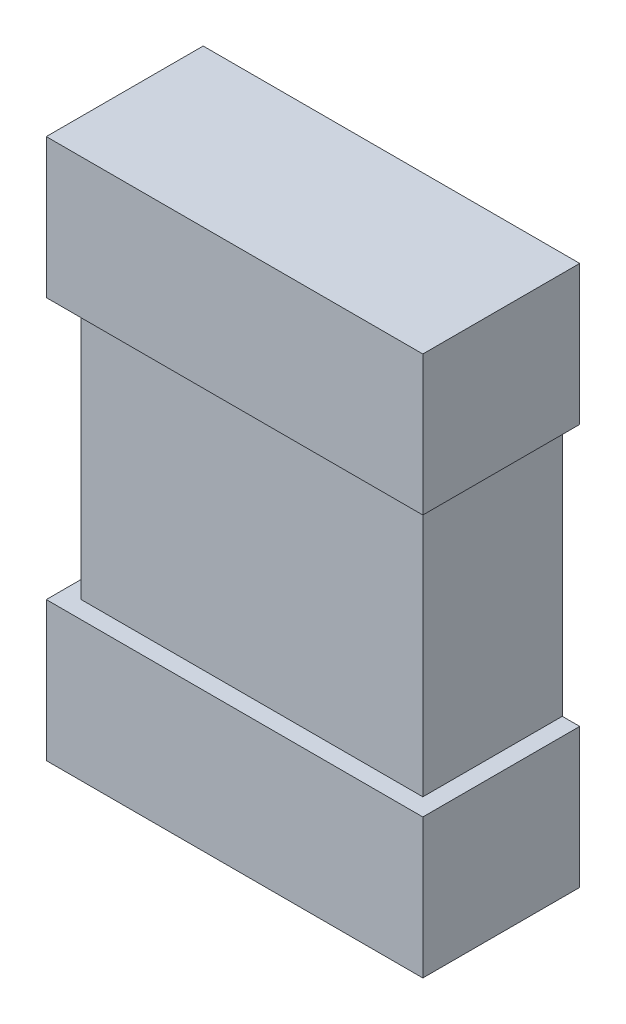
from build123d import *

# Parameters (mm, degrees)
COMPONENT_OUTLINE_W = 1.08
COMPONENT_OUTLINE_H = 1.55
EXTRUDE1_DEPTH      = 0.45
SKETCH2_W           = 0.05
SKETCH2_H           = 0.75
CUT_EXTRUDE1_DEPTH  = 1.45
SKETCH3_W           = 0.05
SKETCH3_H           = 0.75
CUT_EXTRUDE2_DEPTH  = 2.03


with BuildPart() as part:
    # COMPONENT_OUTLINE → Extrude1 (new body)
    with BuildSketch(Plane.XY):
        Rectangle(COMPONENT_OUTLINE_W, COMPONENT_OUTLINE_H)
    extrude(amount=EXTRUDE1_DEPTH)

    # Sketch2 → Cut-Extrude1 (cut, through all)
    with BuildSketch(Plane.XY.offset(0.45)):
        with Locations((-0.515, 0)):
            Rectangle(SKETCH2_W, SKETCH2_H)
        with Locations((0.515, 0)):
            Rectangle(SKETCH2_W, SKETCH2_H)
    extrude(amount=-CUT_EXTRUDE1_DEPTH, mode=Mode.SUBTRACT)

    # Sketch3 → Cut-Extrude2 (cut, through all)
    with BuildSketch(Plane(origin=(0.49, 0, 0), x_dir=(0, 0, -1), z_dir=(1, 0, 0))):
        with Locations((-0.425, 0)):
            Rectangle(SKETCH3_W, SKETCH3_H)
    extrude(amount=-CUT_EXTRUDE2_DEPTH, mode=Mode.SUBTRACT)


solid = part.part
